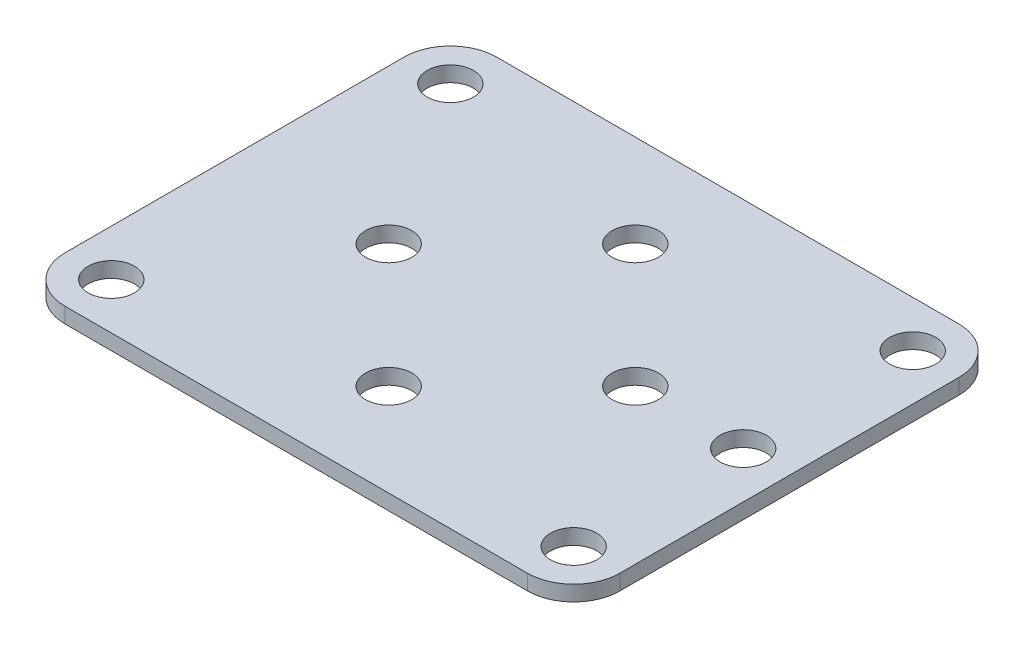
from build123d import *

# Parameters (mm, degrees)
SKETCH1_R           = 1.5
BOSS_EXTRUDE1_DEPTH = 1
SKETCH2_R           = 1.5
CUT_EXTRUDE1_DEPTH  = 10


with BuildPart() as part:
    # Sketch1 → Boss-Extrude1 (new body)
    with BuildSketch(Plane(origin=(0, 0, 0), x_dir=(1, 0, 0), z_dir=(0, 1, 0))):
        with BuildLine():
            Line((3, 0), (33, 0))
            ThreePointArc((33, 0), (35.121320344, 0.878679656), (36, 3))
            Line((36, 3), (36, 25))
            ThreePointArc((36, 25), (35.121320344, 27.121320344), (33, 28))
            Line((33, 28), (3, 28))
            ThreePointArc((3, 28), (0.878679656, 27.121320344), (0, 25))
            Line((0, 25), (0, 3))
            ThreePointArc((0, 3), (0.878679656, 0.878679656), (3, 0))
        make_face()
        with Locations((3, 25)):
            Circle(SKETCH1_R, mode=Mode.SUBTRACT)
        with Locations((3, 3)):
            Circle(SKETCH1_R, mode=Mode.SUBTRACT)
        with Locations((33, 25)):
            Circle(SKETCH1_R, mode=Mode.SUBTRACT)
        with Locations((33, 3)):
            Circle(SKETCH1_R, mode=Mode.SUBTRACT)
        with Locations((18, 22)):
            Circle(SKETCH1_R, mode=Mode.SUBTRACT)
        with Locations((18, 6)):
            Circle(SKETCH1_R, mode=Mode.SUBTRACT)
        with Locations((26, 14)):
            Circle(SKETCH1_R, mode=Mode.SUBTRACT)
        with Locations((10, 14)):
            Circle(SKETCH1_R, mode=Mode.SUBTRACT)
    extrude(amount=BOSS_EXTRUDE1_DEPTH)

    # Sketch2 → Cut-Extrude1 (cut)
    with BuildSketch(Plane(origin=(0, 1, 0), x_dir=(1, 0, 0), z_dir=(0, 1, 0))):
        with Locations((33, 14)):
            Circle(SKETCH2_R)
    extrude(amount=-CUT_EXTRUDE1_DEPTH, mode=Mode.SUBTRACT)


solid = part.part
